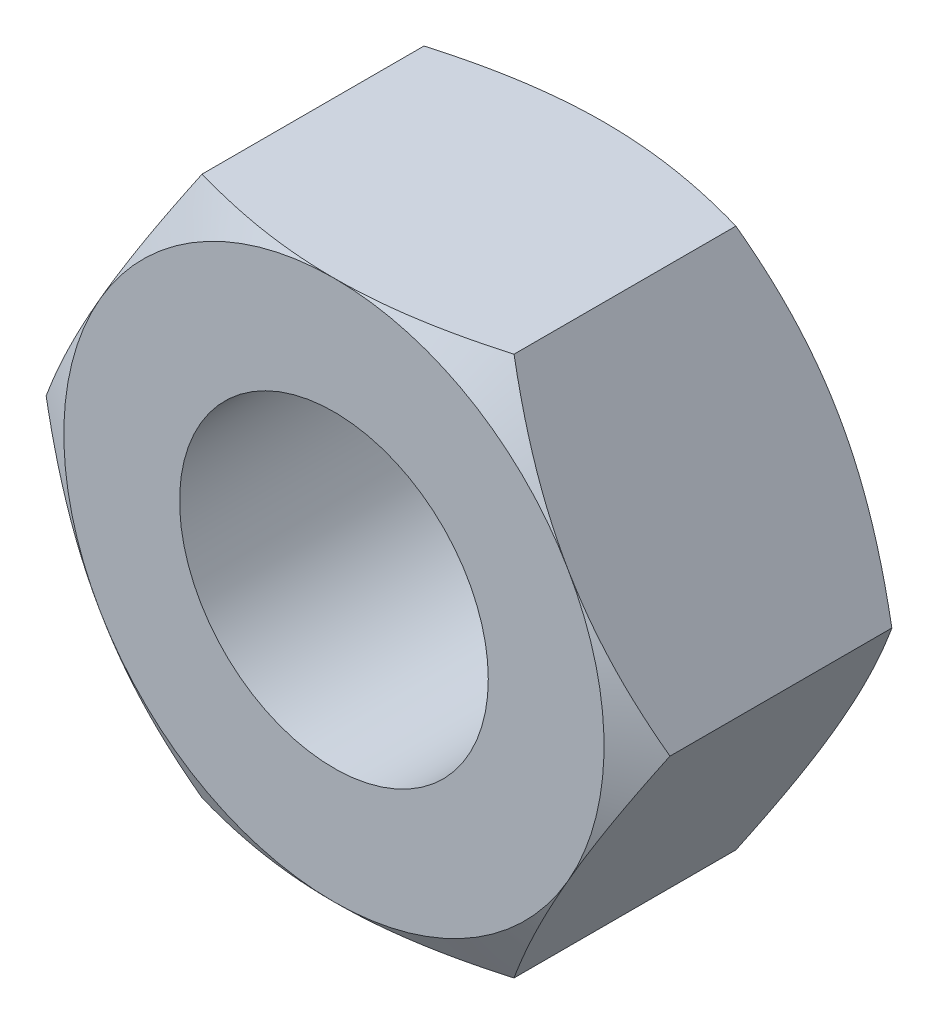
from build123d import *

# Parameters (mm, degrees)
BASE_EXTRUDE_DEPTH = 5.55625
SKETCH4_R          = 3.175
I_D_DEPTH          = 6.55625
SKETCH5_OUTSIDE_W  = 106.392
SKETCH5_OUTSIDE_H  = 104.672
SKETCH5_OUTSIDE_R  = 5.55625
CUT_EXTRUDE3_DEPTH = 25.4
CUT_EXTRUDE3_TAPER = 60
SKETCH6_OUTSIDE_W  = 53.046
SKETCH6_OUTSIDE_H  = 51.326
SKETCH6_OUTSIDE_R  = 5.55625
CUT_EXTRUDE4_DEPTH = 10
CUT_EXTRUDE4_TAPER = 60


with BuildPart() as part:
    # Sketch2 → Base-Extrude (new body)
    with BuildSketch(Plane.XY):
        Polygon((3.207902433, -5.55625), (6.415804866, 0), (3.207902433, 5.55625), (-3.207902433, 5.55625), (-6.415804866, 0), (-3.207902433, -5.55625), align=None)
    extrude(amount=-BASE_EXTRUDE_DEPTH)

    # Sketch4 → I.D. (cut, through all)
    with BuildSketch(Plane.XY):
        Circle(SKETCH4_R)
    extrude(amount=-I_D_DEPTH, mode=Mode.SUBTRACT)

    # Sketch5 outside → Cut-Extrude3 (cut)
    with BuildSketch(Plane(origin=(0, 0, -5.55625), x_dir=(-1, 0, 0), z_dir=(0, 0, -1))):
        Rectangle(SKETCH5_OUTSIDE_W, SKETCH5_OUTSIDE_H)
        Circle(SKETCH5_OUTSIDE_R, mode=Mode.SUBTRACT)
    extrude(amount=-CUT_EXTRUDE3_DEPTH, taper=CUT_EXTRUDE3_TAPER, mode=Mode.SUBTRACT)

    # Sketch6 outside → Cut-Extrude4 (cut)
    with BuildSketch(Plane.XY):
        Rectangle(SKETCH6_OUTSIDE_W, SKETCH6_OUTSIDE_H)
        Circle(SKETCH6_OUTSIDE_R, mode=Mode.SUBTRACT)
    extrude(amount=-CUT_EXTRUDE4_DEPTH, taper=CUT_EXTRUDE4_TAPER, mode=Mode.SUBTRACT)


solid = part.part
